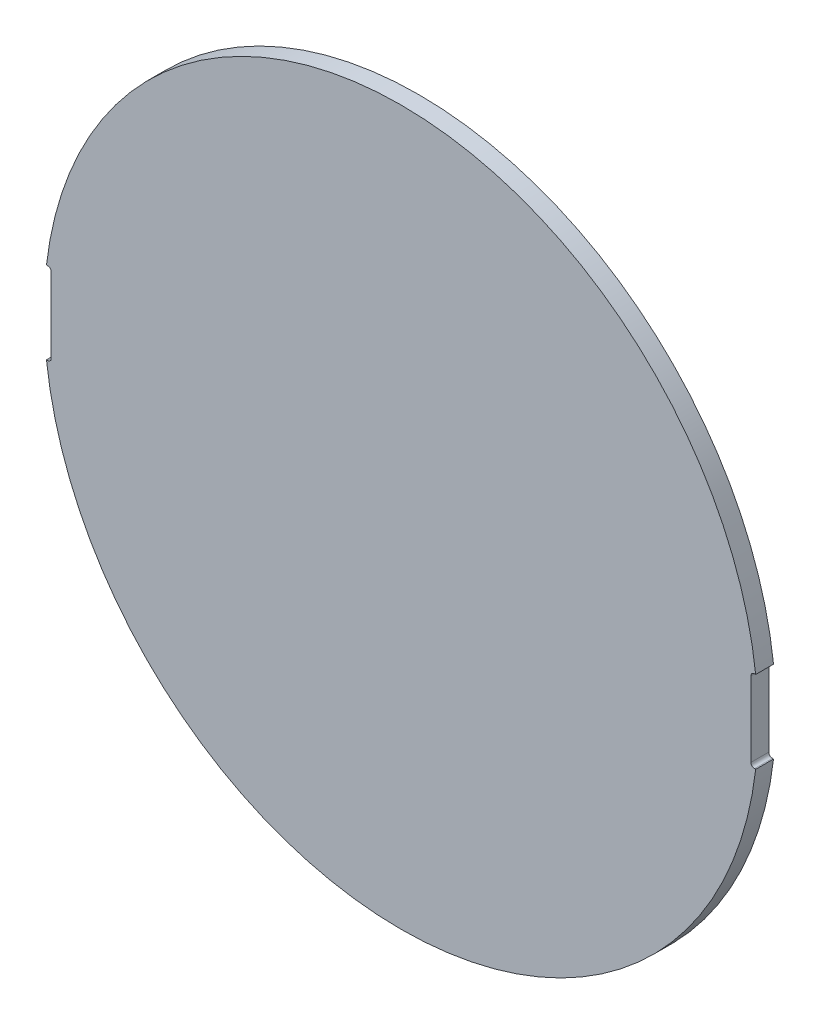
from build123d import *

# Parameters (mm, degrees)
SKETCH1_R           = 20
BOSS_EXTRUDE1_DEPTH = 1
CUT_EXTRUDE1_REACH  = 30.302
CIRPATTERN1_COUNT   = 2


with BuildPart() as part:
    # Sketch1 → Boss-Extrude1 (new body)
    with BuildSketch(Plane.XY):
        Circle(SKETCH1_R)
    extrude(amount=BOSS_EXTRUDE1_DEPTH)

    # Sketch2 → Cut-Extrude1 (cut, up to next)
    with BuildSketch(Plane.XY.offset(1), mode=Mode.PRIVATE) as cut_extrude1_sk1:
        with BuildLine():
            Line((-19.867309833, 2.3), (-19.8, 2.3))
            ThreePointArc((-19.8, 2.3), (-19.658578644, 2.241421356), (-19.6, 2.1))
            Line((-19.6, 2.1), (-19.6, -2.1))
            ThreePointArc((-19.6, -2.1), (-19.658578644, -2.241421356), (-19.8, -2.3))
            Line((-19.8, -2.3), (-19.867309833, -2.3))
            ThreePointArc((-19.867309833, -2.3), (-20, 0), (-19.867309833, 2.3))
        make_face()
    cut_extrude1_tool1 = extrude(cut_extrude1_sk1.sketch, amount=-CUT_EXTRUDE1_REACH, mode=Mode.PRIVATE) & part.part
    cut_extrude1 = cut_extrude1_tool1.solids().sort_by_distance((-19.781547, 0, 1))[0]
    add(cut_extrude1, mode=Mode.SUBTRACT)

    # CirPattern1: Cut-Extrude1 ×2 about axis
    cirpattern1_axis = Axis((0, 0, 1), (0, 0, 1))
    for i in range(1, CIRPATTERN1_COUNT):
        add(cut_extrude1.rotate(cirpattern1_axis, i * 360 / CIRPATTERN1_COUNT), mode=Mode.SUBTRACT)


solid = part.part
